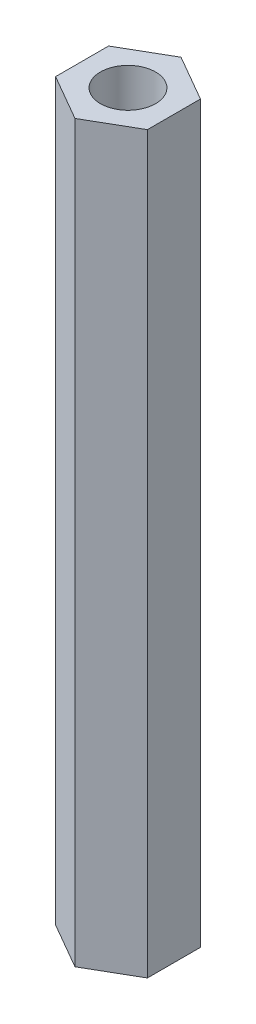
from build123d import *

# Parameters (mm, degrees)
SKETCH_1_R      = 1.5
EXTRUDE_1_DEPTH = 40


with BuildPart() as part:
    # 草圖1 → 填料-伸長1 (new body)
    with BuildSketch(Plane(origin=(0, 0, 0), x_dir=(1, 0, 0), z_dir=(0, 1, 0))):
        Polygon((0, 2.886751346), (-2.5, 1.443375673), (-2.5, -1.443375673), (0, -2.886751346), (2.5, -1.443375673), (2.5, 1.443375673), align=None)
        Circle(SKETCH_1_R, mode=Mode.SUBTRACT)
    extrude(amount=EXTRUDE_1_DEPTH)


solid = part.part
